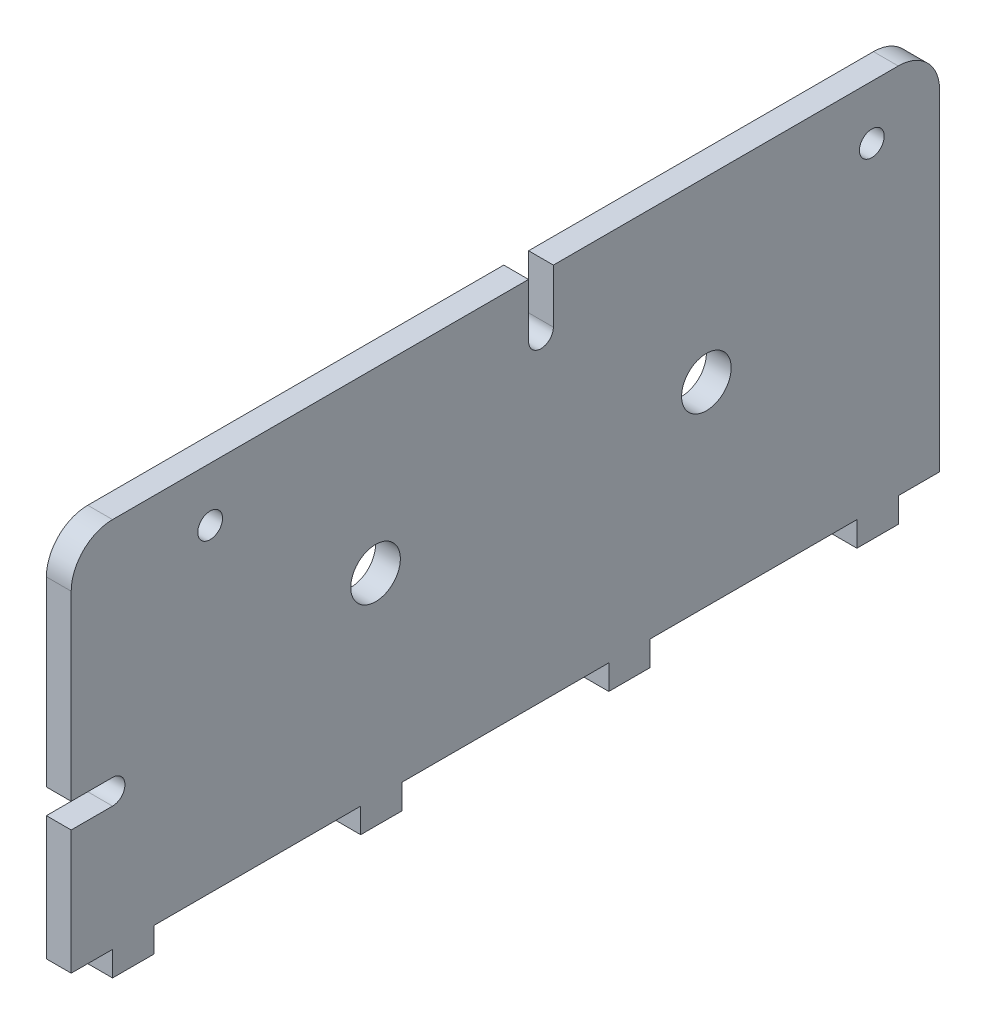
from build123d import *

# Parameters (mm, degrees)
SKETCH1_W           = 105
SKETCH1_H           = 45
BOSS_EXTRUDE1_DEPTH = 3
SKETCH2_R           = 3
SKETCH2_R_2         = 1.5
CUT_EXTRUDE1_DEPTH  = 4
CUT_EXTRUDE2_DEPTH  = 4
FILLET3_R           = 5
SKETCH4_W           = 3
SKETCH4_H           = 5
BOSS_EXTRUDE2_DEPTH = 3
LPATTERN1_COUNT     = 4
LPATTERN1_PITCH     = 30


with BuildPart() as part:
    # Sketch1 → Boss-Extrude1 (new body)
    with BuildSketch(Plane(origin=(0, 0, 0), x_dir=(0, 0, -1), z_dir=(1, 0, 0))):
        with Locations((22.5, 22.5)):
            Rectangle(SKETCH1_W, SKETCH1_H)
    extrude(amount=BOSS_EXTRUDE1_DEPTH)

    # Sketch2 → Cut-Extrude1 (cut, through all)
    with BuildSketch(Plane(origin=(3, 0, 0), x_dir=(0, 0, -1), z_dir=(1, 0, 0))):
        with Locations((6.8, 23.5)):
            Circle(SKETCH2_R)
        with Locations((46.8, 23.5)):
            Circle(SKETCH2_R)
        with Locations((66.8, 38.5)):
            Circle(SKETCH2_R_2)
        with Locations((-13.2, 38.5)):
            Circle(SKETCH2_R_2)
        with BuildLine():
            Line((25.3, 38.5), (25.3, 45))
            Line((25.3, 45), (28.3, 45))
            Line((28.3, 45), (28.3, 38.5))
            ThreePointArc((28.3, 38.5), (26.8, 37), (25.3, 38.5))
        make_face()
    extrude(amount=-CUT_EXTRUDE1_DEPTH, mode=Mode.SUBTRACT)

    # Sketch3 → Cut-Extrude2 (cut, through all)
    with BuildSketch(Plane(origin=(3, 0, 0), x_dir=(0, 0, -1), z_dir=(1, 0, 0))):
        with BuildLine():
            Line((-25, 15), (-30, 15))
            Line((-30, 15), (-30, 18))
            Line((-30, 18), (-25, 18))
            ThreePointArc((-25, 18), (-23.5, 16.5), (-25, 15))
        make_face()
    extrude(amount=-CUT_EXTRUDE2_DEPTH, mode=Mode.SUBTRACT)

    # Fillet3
    fillet3_edges = [part.edges().sort_by_distance(p)[0] for p in [
        (1.5, 45, 30),
        (1.5, 45, -75),
    ]]
    fillet(fillet3_edges, radius=FILLET3_R)

    # Sketch4 → Boss-Extrude2 (add)
    with BuildSketch(Plane(origin=(0, 0, 0), x_dir=(1, 0, 0), z_dir=(0, 1, 0))):
        with Locations((1.5, -22.5)):
            Rectangle(SKETCH4_W, SKETCH4_H)
    boss_extrude2 = extrude(amount=-BOSS_EXTRUDE2_DEPTH)

    # LPattern1: Boss-Extrude2 ×4
    with Locations(*[(0, 0, -i * LPATTERN1_PITCH) for i in range(1, LPATTERN1_COUNT)]):
        add(boss_extrude2)


solid = part.part
